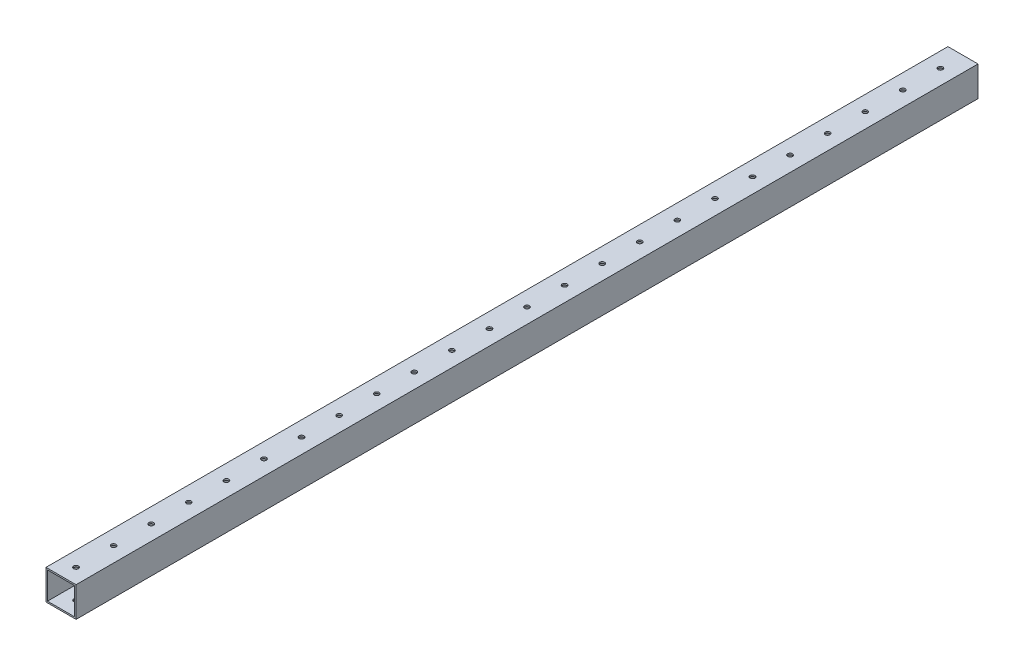
from build123d import *

# Parameters (mm, degrees)
SKETCH_1_W          = 20
SKETCH_1_H          = 20
SKETCH_1_W_2        = 18
SKETCH_1_H_2        = 18
EXTRUDE_1_DEPTH     = 600
SKETCH_2_R          = 1.6
CUT_EXTRUDE_1_DEPTH = 21


with BuildPart() as part:
    # 草图1 → 凸台-拉伸1 (new body)
    with BuildSketch(Plane.XY):
        Rectangle(SKETCH_1_W, SKETCH_1_H)
        Rectangle(SKETCH_1_W_2, SKETCH_1_H_2, mode=Mode.SUBTRACT)
    extrude(amount=EXTRUDE_1_DEPTH)

    # 草图2 → 切除-拉伸1 (cut, through all)
    with BuildSketch(Plane(origin=(0, 10, 0), x_dir=(1, 0, 0), z_dir=(0, 1, 0))):
        with Locations((0, -15)):
            Circle(SKETCH_2_R)
        with Locations((0, -40)):
            Circle(SKETCH_2_R)
        with Locations((0, -65)):
            Circle(SKETCH_2_R)
        with Locations((0, -90)):
            Circle(SKETCH_2_R)
        with Locations((0, -115)):
            Circle(SKETCH_2_R)
        with Locations((0, -140)):
            Circle(SKETCH_2_R)
        with Locations((0, -165)):
            Circle(SKETCH_2_R)
        with Locations((0, -190)):
            Circle(SKETCH_2_R)
        with Locations((0, -215)):
            Circle(SKETCH_2_R)
        with Locations((0, -240)):
            Circle(SKETCH_2_R)
        with Locations((0, -265)):
            Circle(SKETCH_2_R)
        with Locations((0, -290)):
            Circle(SKETCH_2_R)
        with Locations((0, -315)):
            Circle(SKETCH_2_R)
        with Locations((0, -340)):
            Circle(SKETCH_2_R)
        with Locations((0, -365)):
            Circle(SKETCH_2_R)
        with Locations((0, -390)):
            Circle(SKETCH_2_R)
        with Locations((0, -415)):
            Circle(SKETCH_2_R)
        with Locations((0, -440)):
            Circle(SKETCH_2_R)
        with Locations((0, -465)):
            Circle(SKETCH_2_R)
        with Locations((0, -490)):
            Circle(SKETCH_2_R)
        with Locations((0, -515)):
            Circle(SKETCH_2_R)
        with Locations((0, -540)):
            Circle(SKETCH_2_R)
        with Locations((0, -565)):
            Circle(SKETCH_2_R)
        with Locations((0, -590)):
            Circle(SKETCH_2_R)
    extrude(amount=-CUT_EXTRUDE_1_DEPTH, mode=Mode.SUBTRACT)


solid = part.part
